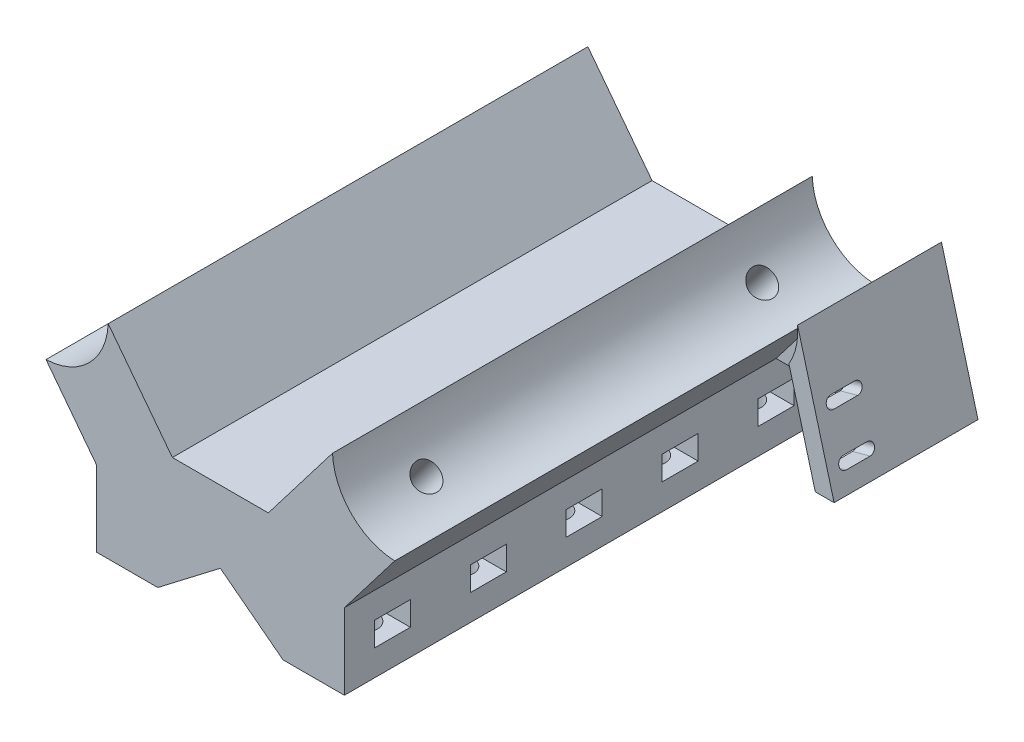
from build123d import *

# Parameters (mm, degrees)
SALIENTE_EXTRUIR1_DEPTH = 100
CORTAR_EXTRUIR2_DEPTH   = 101
CROQUIS4_R              = 5
CORTAR_EXTRUIR3_DEPTH   = 5
CROQUIS5_R              = 2.5
CORTAR_EXTRUIR4_DEPTH   = 55
CROQUIS6_R              = 5
CORTAR_EXTRUIR5_DEPTH   = 5
CROQUIS7_R              = 2.75
CORTAR_EXTRUIR6_DEPTH   = 55
CROQUIS8_R              = 2.75
CORTAR_EXTRUIR7_DEPTH   = 15
CROQUIS9_W              = 7.5
CROQUIS9_H              = 5
CORTAR_EXTRUIR8_DEPTH   = 12
CROQUIS10_W             = 7.5
CROQUIS10_H             = 5
CORTAR_EXTRUIR9_DEPTH   = 12
SALIENTE_EXTRUIR2_DEPTH = 10
SALIENTE_EXTRUIR3_DEPTH = 20
CORTAR_EXTRUIR10_DEPTH  = 10


with BuildPart() as part:
    # Croquis1 → Saliente-Extruir1 (new body)
    with BuildSketch(Plane.XY):
        with BuildLine():
            Line((-25.854679659, -27.188557242), (-25.854679659, -43))
            Line((-25.854679659, -43), (25.854679659, -43))
            Line((25.854679659, -43), (25.854679659, -27.188557242))
            Line((25.854679659, -27.188557242), (36.348456911, -13.489727661))
            ThreePointArc((36.348456911, -13.489727661), (27.329058454, -9.545941546), (23.385272339, -0.526543089))
            Line((23.385272339, -0.526543089), (10, -18))
            Line((10, -18), (-10, -18))
            Line((-10, -18), (-23.385272339, -0.526543089))
            ThreePointArc((-23.385272339, -0.526543089), (-27.329058454, -9.545941546), (-36.348456911, -13.489727661))
            Line((-36.348456911, -13.489727661), (-25.854679659, -27.188557242))
        make_face()
    extrude(amount=SALIENTE_EXTRUIR1_DEPTH)

    # Croquis3 → Cortar-Extruir2 (cut, through all)
    with BuildSketch(Plane.XY.offset(100)):
        Polygon((0, -33), (-29.159434589, -55.337135416), (29.159434589, -55.337135416), align=None)
    extrude(amount=-CORTAR_EXTRUIR2_DEPTH, mode=Mode.SUBTRACT)

    # Croquis4 → Cortar-Extruir3 (cut)
    with BuildSketch(Plane(origin=(15.930802982, -20.796453926, 0), x_dir=(-0.793848583, -0.608115471, 0), z_dir=(0.608115471, -0.793848583, 0))):
        with Locations((28.28993322, -85)):
            Circle(CROQUIS4_R)
        with Locations((28.28993322, -15)):
            Circle(CROQUIS4_R)
    extrude(amount=-CORTAR_EXTRUIR3_DEPTH, mode=Mode.SUBTRACT)

    # Croquis5 → Cortar-Extruir4 (cut)
    with BuildSketch(Plane(origin=(12.890225626, -16.827211008, 0), x_dir=(-0.793848583, -0.608115471, 0), z_dir=(0.608115471, -0.793848583, 0))):
        with Locations((28.28993322, -85)):
            Circle(CROQUIS5_R)
        with Locations((28.28993322, -15)):
            Circle(CROQUIS5_R)
    extrude(amount=-CORTAR_EXTRUIR4_DEPTH, mode=Mode.SUBTRACT)

    # Croquis6 → Cortar-Extruir5 (cut)
    with BuildSketch(Plane(origin=(-15.930802982, -20.796453926, 0), x_dir=(0.793848583, -0.608115471, 0), z_dir=(-0.608115471, -0.793848583, 0))):
        with Locations((28.28993322, 85)):
            Circle(CROQUIS6_R)
        with Locations((28.28993322, 15)):
            Circle(CROQUIS6_R)
    extrude(amount=-CORTAR_EXTRUIR5_DEPTH, mode=Mode.SUBTRACT)

    # Croquis7 → Cortar-Extruir6 (cut)
    with BuildSketch(Plane(origin=(-12.890225626, -16.827211008, 0), x_dir=(0.793848583, -0.608115471, 0), z_dir=(-0.608115471, -0.793848583, 0))):
        with Locations((28.28993322, 85)):
            Circle(CROQUIS7_R)
        with Locations((28.28993322, 15)):
            Circle(CROQUIS7_R)
    extrude(amount=-CORTAR_EXTRUIR6_DEPTH, mode=Mode.SUBTRACT)

    # Croquis8 → Cortar-Extruir7 (cut)
    with BuildSketch(Plane.XZ.offset(43)):
        with Locations((-20, 90)):
            Circle(CROQUIS8_R)
        with Locations((20, 90)):
            Circle(CROQUIS8_R)
        with Locations((20, 70)):
            Circle(CROQUIS8_R)
        with Locations((-20, 70)):
            Circle(CROQUIS8_R)
        with Locations((20, 50)):
            Circle(CROQUIS8_R)
        with Locations((-20, 50)):
            Circle(CROQUIS8_R)
        with Locations((20, 30)):
            Circle(CROQUIS8_R)
        with Locations((-20, 30)):
            Circle(CROQUIS8_R)
        with Locations((20, 10)):
            Circle(CROQUIS8_R)
        with Locations((-20, 10)):
            Circle(CROQUIS8_R)
    extrude(amount=-CORTAR_EXTRUIR7_DEPTH, mode=Mode.SUBTRACT)

    # Croquis9 → Cortar-Extruir8 (cut)
    with BuildSketch(Plane(origin=(25.854679659, 0, 0), x_dir=(0, 0, -1), z_dir=(1, 0, 0))):
        with Locations((-90, -35.094278621)):
            Rectangle(CROQUIS9_W, CROQUIS9_H)
        with Locations((-70, -35.094278621)):
            Rectangle(CROQUIS9_W, CROQUIS9_H)
        with Locations((-50, -35.094278621)):
            Rectangle(CROQUIS9_W, CROQUIS9_H)
        with Locations((-30, -35.094278621)):
            Rectangle(CROQUIS9_W, CROQUIS9_H)
        with Locations((-10, -35.094278621)):
            Rectangle(CROQUIS9_W, CROQUIS9_H)
    extrude(amount=-CORTAR_EXTRUIR8_DEPTH, mode=Mode.SUBTRACT)

    # Croquis10 → Cortar-Extruir9 (cut)
    with BuildSketch(Plane.ZY.offset(25.854679659)):
        with Locations((90, -35.094278621)):
            Rectangle(CROQUIS10_W, CROQUIS10_H)
        with Locations((70, -35.094278621)):
            Rectangle(CROQUIS10_W, CROQUIS10_H)
        with Locations((50, -35.094278621)):
            Rectangle(CROQUIS10_W, CROQUIS10_H)
        with Locations((30, -35.094278621)):
            Rectangle(CROQUIS10_W, CROQUIS10_H)
        with Locations((10, -35.094278621)):
            Rectangle(CROQUIS10_W, CROQUIS10_H)
    extrude(amount=-CORTAR_EXTRUIR9_DEPTH, mode=Mode.SUBTRACT)

    # Croquis11 → Saliente-Extruir2 (add)
    with BuildSketch(Plane(origin=(0, 0, 0), x_dir=(-1, 0, 0), z_dir=(0, 0, -1))):
        with BuildLine():
            Line((-50.332788561, 1.06673664), (-57.946904644, -27.188557242))
            Line((-57.946904644, -27.188557242), (-25.854679659, -27.188557242))
            Line((-25.854679659, -27.188557242), (-36.348456911, -13.489727661))
            ThreePointArc((-36.348456911, -13.489727661), (-46.610344914, -9.35270332), (-50.332788561, 1.06673664))
        make_face()
    extrude(amount=-SALIENTE_EXTRUIR2_DEPTH)

    # Croquis12 → Saliente-Extruir3 (add)
    with BuildSketch(Plane.XY.offset(10)):
        with BuildLine():
            Line((54.026124626, -27.188557242), (48.533618564, -6.806365636))
            ThreePointArc((48.533618564, -6.806365636), (50.035733702, -3.007505349), (50.332788561, 1.06673664))
            Line((50.332788561, 1.06673664), (57.946904644, -27.188557242))
            Line((57.946904644, -27.188557242), (54.026124626, -27.188557242))
        make_face()
    extrude(amount=SALIENTE_EXTRUIR3_DEPTH)

    # Croquis13 → Cortar-Extruir10 (cut)
    with BuildSketch(Plane(origin=(47.193210715, 12.717425139, 0), x_dir=(0, 0, -1), z_dir=(0.965556357, 0.260194009, 0))):
        with BuildLine():
            Line((-26.5, -35.129521687), (-21.5, -35.129521687))
            ThreePointArc((-21.5, -35.129521687), (-20.3, -36.329521687), (-21.5, -37.529521687))
            Line((-21.5, -37.529521687), (-26.5, -37.529521687))
            ThreePointArc((-26.5, -37.529521687), (-27.7, -36.329521687), (-26.5, -35.129521687))
        make_face()
        with BuildLine():
            Line((-26.5, -25.129521687), (-21.5, -25.129521687))
            ThreePointArc((-21.5, -25.129521687), (-20.3, -26.329521687), (-21.5, -27.529521687))
            Line((-21.5, -27.529521687), (-26.5, -27.529521687))
            ThreePointArc((-26.5, -27.529521687), (-27.7, -26.329521687), (-26.5, -25.129521687))
        make_face()
    extrude(amount=-CORTAR_EXTRUIR10_DEPTH, mode=Mode.SUBTRACT)


solid = part.part
